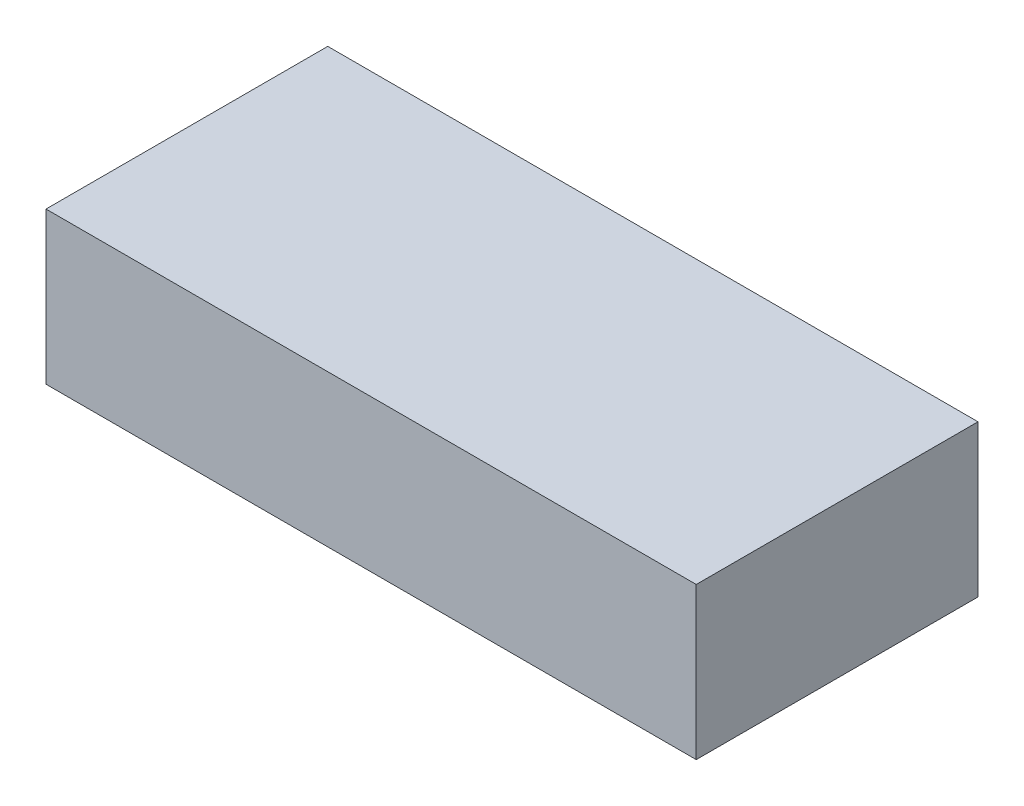
from build123d import *

# Parameters (mm, degrees)
SKETCH1_W           = 150
SKETCH1_H           = 65
BOSS_EXTRUDE1_DEPTH = 35
SKETCH2_W           = 143.904
SKETCH2_H           = 58.904
CUT_EXTRUDE1_DEPTH  = 28.4


with BuildPart() as part:
    # Sketch1 → Boss-Extrude1 (new body)
    with BuildSketch(Plane(origin=(0, 0, 0), x_dir=(1, 0, 0), z_dir=(0, 1, 0))):
        Rectangle(SKETCH1_W, SKETCH1_H)
    extrude(amount=BOSS_EXTRUDE1_DEPTH)

    # Sketch2 → Cut-Extrude1 (cut)
    with BuildSketch(Plane.XZ):
        Rectangle(SKETCH2_W, SKETCH2_H)
    extrude(amount=-CUT_EXTRUDE1_DEPTH, mode=Mode.SUBTRACT)


solid = part.part
